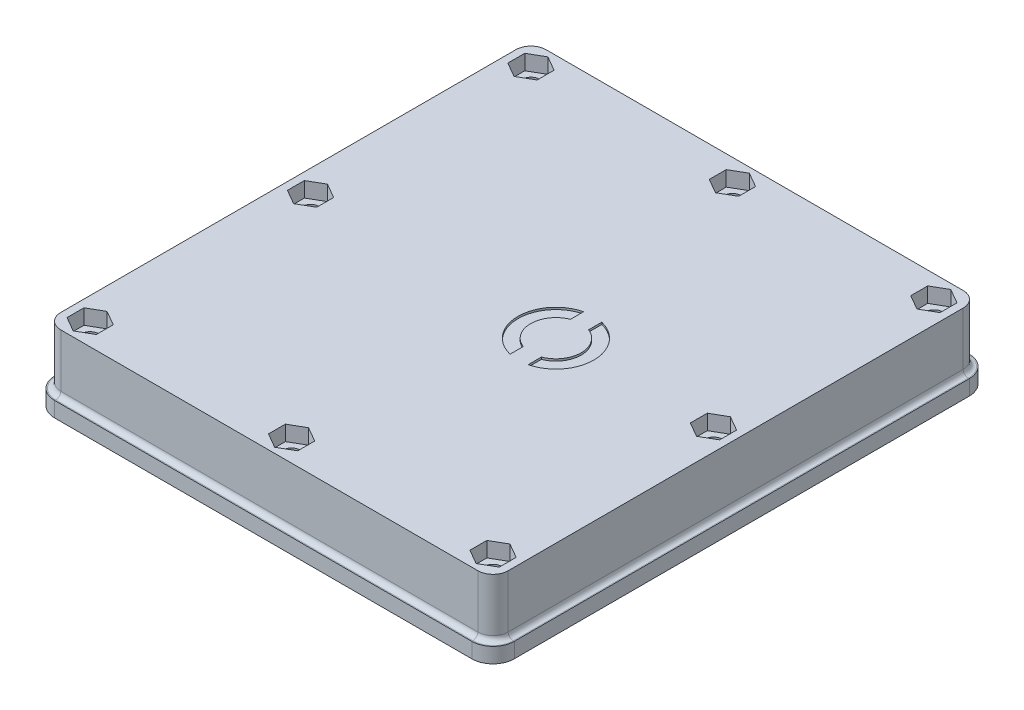
from build123d import *

# Parameters (mm, degrees)
SKETCH_1_R          = 1.7
EXTRUDE_1_DEPTH     = 10
SKETCH_2_R          = 1.7
EXTRUDE_2_DEPTH     = 2.5
FILLET_1_R          = 9.5
FILLET_2_R          = 9.5
FILLET_3_R          = 9.5
SKETCH_3_R          = 5
SKETCH_3_R_2        = 3
EXTRUDE_3_DEPTH     = 3
CUT_EXTRUDE_1_DEPTH = 0.4
CUT_EXTRUDE_2_DEPTH = 3
SKETCH_6_W          = 8
SKETCH_6_H          = 9.5
SKETCH_6_W_2        = 2.5
SKETCH_6_H_2        = 30
EXTRUDE_4_DEPTH     = 5
EXTRUDE_5_DEPTH     = 2
EXTRUDE_1_2_DEPTH   = 2
EXTRUDE_3_2_DEPTH   = 3
FILLET_4_R          = 1


with BuildPart() as part:
    # Эскиз1 → Extrude 1 (new body)
    with BuildSketch(Plane(origin=(0, 0, 0), x_dir=(1, 0, 0), z_dir=(0, 1, 0))):
        with BuildLine():
            ThreePointArc((-44.999265675, -44.551130115), (-44.120586019, -46.672450458), (-41.999265675, -47.551130115))
            Line((-41.999265675, -47.551130115), (40.500734325, -47.551130115))
            ThreePointArc((40.500734325, -47.551130115), (42.622054669, -46.672450458), (43.500734325, -44.551130115))
            Line((43.500734325, -44.551130115), (43.500734325, 45.448869885))
            ThreePointArc((43.500734325, 45.448869885), (42.622054669, 47.570190229), (40.500734325, 48.448869885))
            Line((40.500734325, 48.448869885), (-41.999265675, 48.448869885))
            ThreePointArc((-41.999265675, 48.448869885), (-44.120586019, 47.570190229), (-44.999265675, 45.448869885))
            Line((-44.999265675, 45.448869885), (-44.999265675, -44.551130115))
        make_face()
        with Locations((-40.599265675, -43.151130115)):
            Circle(SKETCH_1_R, mode=Mode.SUBTRACT)
        with Locations((-0.749265675, -43.151130115)):
            Circle(SKETCH_1_R, mode=Mode.SUBTRACT)
        with Locations((39.100734325, -43.151130115)):
            Circle(SKETCH_1_R, mode=Mode.SUBTRACT)
        with Locations((-40.599265675, 0.448869885)):
            Circle(SKETCH_1_R, mode=Mode.SUBTRACT)
        with Locations((-40.599265675, 44.048869885)):
            Circle(SKETCH_1_R, mode=Mode.SUBTRACT)
        with Locations((-0.749265675, 44.048869885)):
            Circle(SKETCH_1_R, mode=Mode.SUBTRACT)
        Polygon((-17.403857393, -29.173018851), (-17.403857393, -31.551130115), (-17.403857393, -39.173018851), (-36.903857393, -39.173018851), (-36.903857393, 41.326981149), (-17.403857393, 41.326981149), (-17.403857393, 40.448869885), (-17.403857393, 31.326981149), (-15.999265675, 31.326981149), (-15.999265675, 40.448869885), (38.000734325, 40.448869885), (38.000734325, 10.448869885), (35.500734325, 10.448869885), (35.500734325, -29.051130115), (35.500734325, -30.051130115), (35.500734325, -39.551130115), (27.500734325, -39.551130115), (27.500734325, -30.051130115), (21.000734325, -30.051130115), (21.000734325, -31.551130115), (-15.999265675, -31.551130115), (-15.999265675, -29.173018851), align=None, mode=Mode.SUBTRACT)
        with Locations((39.100734325, 0.448869885)):
            Circle(SKETCH_1_R, mode=Mode.SUBTRACT)
        with Locations((39.100734325, 44.048869885)):
            Circle(SKETCH_1_R, mode=Mode.SUBTRACT)
    extrude(amount=EXTRUDE_1_DEPTH)

    # Эскиз2 → Бобышка-Вытянуть2 (add)
    with BuildSketch(Plane(origin=(0, 10, 0), x_dir=(1, 0, 0), z_dir=(0, 1, 0))):
        with BuildLine():
            Line((43.500734325, 45.448869885), (43.500734325, -44.551130115))
            ThreePointArc((43.500734325, -44.551130115), (42.622054669, -46.672450458), (40.500734325, -47.551130115))
            Line((40.500734325, -47.551130115), (-41.999265675, -47.551130115))
            ThreePointArc((-41.999265675, -47.551130115), (-44.120586019, -46.672450458), (-44.999265675, -44.551130115))
            Line((-44.999265675, -44.551130115), (-44.999265675, 45.448869885))
            ThreePointArc((-44.999265675, 45.448869885), (-44.120586019, 47.570190229), (-41.999265675, 48.448869885))
            Line((-41.999265675, 48.448869885), (40.500734325, 48.448869885))
            ThreePointArc((40.500734325, 48.448869885), (42.622054669, 47.570190229), (43.500734325, 45.448869885))
        make_face()
        with Locations((39.100734325, 0.448869885)):
            Circle(SKETCH_2_R, mode=Mode.SUBTRACT)
        with Locations((39.100734325, -43.151130115)):
            Circle(SKETCH_2_R, mode=Mode.SUBTRACT)
        with Locations((-0.749265675, -43.151130115)):
            Circle(SKETCH_2_R, mode=Mode.SUBTRACT)
        with Locations((-40.599265675, -43.151130115)):
            Circle(SKETCH_2_R, mode=Mode.SUBTRACT)
        with Locations((-40.599265675, 0.448869885)):
            Circle(SKETCH_2_R, mode=Mode.SUBTRACT)
        with Locations((39.100734325, 44.048869885)):
            Circle(SKETCH_2_R, mode=Mode.SUBTRACT)
        with Locations((-0.749265675, 44.048869885)):
            Circle(SKETCH_2_R, mode=Mode.SUBTRACT)
        with Locations((-40.599265675, 44.048869885)):
            Circle(SKETCH_2_R, mode=Mode.SUBTRACT)
    extrude(amount=EXTRUDE_2_DEPTH)

    # Скругление1
    fillet_1_edges = [part.edges().sort_by_distance(p)[0] for p in [
        (-36.903857393, 10, -1.076981149),
    ]]
    fillet(fillet_1_edges, radius=FILLET_1_R)

    # Скругление2
    fillet_2_edges = [part.edges().sort_by_distance(p)[0] for p in [
        (-17.403857393, 10, 34.173018851),
    ]]
    fillet(fillet_2_edges, radius=FILLET_2_R)

    # Скругление3
    fillet_3_edges = [part.edges().sort_by_distance(p)[0] for p in [
        (-17.403857393, 10, -36.326981149),
    ]]
    fillet(fillet_3_edges, radius=FILLET_3_R)

    # Эскиз3 → Extrude 3 (add)
    with BuildSketch(Plane.XZ.offset(-10)):
        with Locations((9.100734325, -2.448869885)):
            Circle(SKETCH_3_R)
        with Locations((9.100734325, -2.448869885)):
            Circle(SKETCH_3_R_2, mode=Mode.SUBTRACT)
    extrude(amount=EXTRUDE_3_DEPTH)

    # Эскиз4 → Вырез-Вытянуть1 (cut)
    with BuildSketch(Plane(origin=(0, 12.5, 0), x_dir=(1, 0, 0), z_dir=(0, 1, 0))):
        with BuildLine():
            Line((6.592743591, 7.281943928), (6.592743591, 4.666551979))
            ThreePointArc((6.592743591, 4.666551979), (3.388096655, 0), (6.592743591, -4.666551979))
            Line((6.592743591, -4.666551979), (6.592743591, -7.281943928))
            ThreePointArc((6.592743591, -7.281943928), (0.888096655, 0), (6.592743591, 7.281943928))
        make_face()
        with BuildLine():
            Line((10.18344972, 7.281943928), (10.18344972, 4.666551979))
            ThreePointArc((10.18344972, 4.666551979), (13.388096655, 0), (10.18344972, -4.666551979))
            Line((10.18344972, -4.666551979), (10.18344972, -7.281943928))
            ThreePointArc((10.18344972, -7.281943928), (15.888096655, 0), (10.18344972, 7.281943928))
        make_face()
    extrude(amount=-CUT_EXTRUDE_1_DEPTH, mode=Mode.SUBTRACT)

    # Эскиз5 → Вырез-Вытянуть2 (cut)
    with BuildSketch(Plane(origin=(0, 12.5, 0), x_dir=(1, 0, 0), z_dir=(0, 1, 0))):
        Polygon((-40.599265675, 40.700238324), (-37.699265675, 42.374554105), (-37.699265675, 45.723185666), (-40.599265675, 47.397501447), (-43.499265675, 45.723185666), (-43.499265675, 42.374554105), align=None)
        Polygon((-0.749265675, 40.700238324), (2.150734325, 42.374554105), (2.150734325, 45.723185666), (-0.749265675, 47.397501447), (-3.649265675, 45.723185666), (-3.649265675, 42.374554105), align=None)
        Polygon((-40.599265675, 3.797501447), (-43.499265675, 2.123185666), (-43.499265675, -1.225445895), (-40.599265675, -2.899761676), (-37.699265675, -1.225445895), (-37.699265675, 2.123185666), align=None)
        Polygon((36.200734325, 2.123185666), (39.100734325, 3.797501447), (42.000734325, 2.123185666), (42.000734325, -1.225445895), (39.100734325, -2.899761676), (36.200734325, -1.225445895), align=None)
        Polygon((42.000734325, 42.374554105), (39.100734325, 40.700238324), (36.200734325, 42.374554105), (36.200734325, 45.723185666), (39.100734325, 47.397501447), (42.000734325, 45.723185666), align=None)
        Polygon((39.100734325, -39.802498553), (36.200734325, -41.476814334), (36.200734325, -44.825445895), (39.100734325, -46.499761676), (42.000734325, -44.825445895), (42.000734325, -41.476814334), align=None)
        Polygon((-3.649265675, -41.476814334), (-0.749265675, -39.802498553), (2.150734325, -41.476814334), (2.150734325, -44.825445895), (-0.749265675, -46.499761676), (-3.649265675, -44.825445895), align=None)
        Polygon((-43.499265675, -41.476814334), (-40.599265675, -39.802498553), (-37.699265675, -41.476814334), (-37.699265675, -44.825445895), (-40.599265675, -46.499761676), (-43.499265675, -44.825445895), align=None)
    extrude(amount=-CUT_EXTRUDE_2_DEPTH, mode=Mode.SUBTRACT)

    # Эскиз6 → Бобышка-Вытянуть4 (add)
    with BuildSketch(Plane.XZ.offset(-10)):
        with Locations((31.500734325, 34.801130115)):
            Rectangle(SKETCH_6_W, SKETCH_6_H)
        with Locations((36.750734325, -25.448869885)):
            Rectangle(SKETCH_6_W_2, SKETCH_6_H_2)
    extrude(amount=EXTRUDE_4_DEPTH)

    # Эскиз8 → Бобышка-Вытянуть5 (add)
    with BuildSketch(Plane.XZ.offset(-10)):
        with BuildLine():
            Line((35.500734325, -5.248869885), (35.500734325, 4.351130115))
            ThreePointArc((35.500734325, 4.351130115), (33.100734325, -0.448869885), (35.500734325, -5.248869885))
        make_face()
        with BuildLine():
            Line((-5.549265675, -40.448869885), (4.050734325, -40.448869885))
            ThreePointArc((4.050734325, -40.448869885), (-0.749265675, -38.048869885), (-5.549265675, -40.448869885))
        make_face()
    extrude(amount=EXTRUDE_5_DEPTH)

    # Эскиз9 → Extrude 1 2 (add)
    with BuildSketch(Plane.XZ):
        with BuildLine():
            Line((-44.999265675, 44.551130115), (-44.999265675, -45.448869885))
            ThreePointArc((-44.999265675, -45.448869885), (-44.120586019, -47.570190229), (-41.999265675, -48.448869885))
            Line((-41.999265675, -48.448869885), (40.500734325, -48.448869885))
            ThreePointArc((40.500734325, -48.448869885), (42.622054669, -47.570190229), (43.500734325, -45.448869885))
            Line((43.500734325, -45.448869885), (43.500734325, 44.551130115))
            ThreePointArc((43.500734325, 44.551130115), (42.622054669, 46.672450458), (40.500734325, 47.551130115))
            Line((40.500734325, 47.551130115), (-41.999265675, 47.551130115))
            ThreePointArc((-41.999265675, 47.551130115), (-44.120586019, 46.672450458), (-44.999265675, 44.551130115))
        make_face()
        with BuildLine():
            Line((-43.699265675, 44.551130115), (-43.699265675, -45.448869885))
            ThreePointArc((-43.699265675, -45.448869885), (-43.201347203, -46.650951413), (-41.999265675, -47.148869885))
            Line((-41.999265675, -47.148869885), (40.500734325, -47.148869885))
            ThreePointArc((40.500734325, -47.148869885), (41.702815853, -46.650951413), (42.200734325, -45.448869885))
            Line((42.200734325, -45.448869885), (42.200734325, 44.551130115))
            ThreePointArc((42.200734325, 44.551130115), (41.702815853, 45.753211643), (40.500734325, 46.251130115))
            Line((40.500734325, 46.251130115), (-41.999265675, 46.251130115))
            ThreePointArc((-41.999265675, 46.251130115), (-43.201347203, 45.753211643), (-43.699265675, 44.551130115))
        make_face(mode=Mode.SUBTRACT)
    extrude(amount=EXTRUDE_1_2_DEPTH)

    # Эскиз11 → Extrude 3 2 (add)
    with BuildSketch(Plane.XZ.offset(2)):
        with BuildLine():
            Line((-41.999265675, -49.648869885), (40.500734325, -49.648869885))
            ThreePointArc((40.500734325, -49.648869885), (43.470582806, -48.418718366), (44.700734325, -45.448869885))
            Line((44.700734325, -45.448869885), (44.700734325, 44.551130115))
            ThreePointArc((44.700734325, 44.551130115), (43.470582806, 47.520978596), (40.500734325, 48.751130115))
            Line((40.500734325, 48.751130115), (-41.999265675, 48.751130115))
            ThreePointArc((-41.999265675, 48.751130115), (-44.969114156, 47.520978596), (-46.199265675, 44.551130115))
            Line((-46.199265675, 44.551130115), (-46.199265675, -45.448869885))
            ThreePointArc((-46.199265675, -45.448869885), (-44.969114156, -48.418718366), (-41.999265675, -49.648869885))
        make_face()
        with BuildLine():
            Line((-41.999265675, -47.148869885), (40.500734325, -47.148869885))
            ThreePointArc((40.500734325, -47.148869885), (41.702815853, -46.650951413), (42.200734325, -45.448869885))
            Line((42.200734325, -45.448869885), (42.200734325, 44.551130115))
            ThreePointArc((42.200734325, 44.551130115), (41.702815853, 45.753211643), (40.500734325, 46.251130115))
            Line((40.500734325, 46.251130115), (-41.999265675, 46.251130115))
            ThreePointArc((-41.999265675, 46.251130115), (-43.201347203, 45.753211643), (-43.699265675, 44.551130115))
            Line((-43.699265675, 44.551130115), (-43.699265675, -45.448869885))
            ThreePointArc((-43.699265675, -45.448869885), (-43.201347203, -46.650951413), (-41.999265675, -47.148869885))
        make_face(mode=Mode.SUBTRACT)
    extrude(amount=-EXTRUDE_3_2_DEPTH)

    # Скругление4
    fillet_4_edges = [part.edges().sort_by_distance(p)[0] for p in [
        (42.622054669, 1, -47.570190229),
        (42.622054669, 1, 46.672450458),
        (-0.749265675, 1, 47.551130115),
        (-44.120586019, 1, 46.672450458),
        (-44.999265675, 1, -0.448869885),
        (-44.120586019, 1, -47.570190229),
        (-0.749265675, 1, -48.448869885),
        (43.500734325, 1, -0.448869885),
    ]]
    fillet(fillet_4_edges, radius=FILLET_4_R)


solid = part.part
